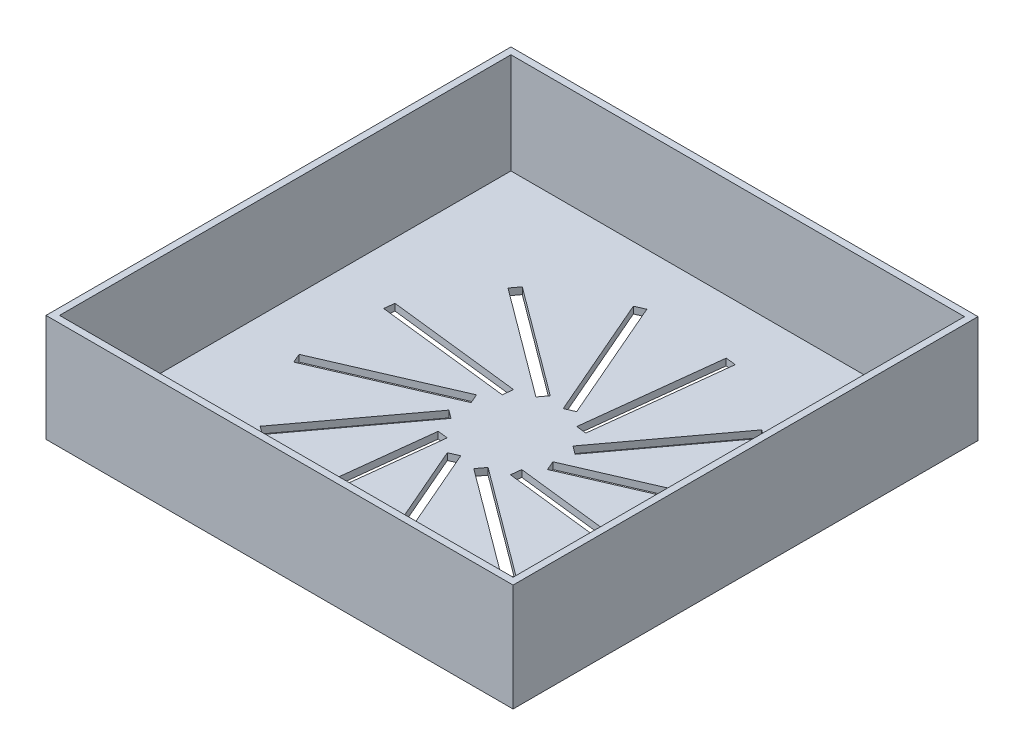
from build123d import *

# Parameters (mm, degrees)
SKETCH1_W           = 55.245
SKETCH1_H           = 54.991
BOSS_EXTRUDE1_DEPTH = 12.7
SKETCH2_W           = 53.645
SKETCH2_H           = 53.391
CUT_EXTRUDE1_DEPTH  = 11.9
CUT_EXTRUDE2_DEPTH  = 11.9


with BuildPart() as part:
    # Sketch1 → Boss-Extrude1 (new body)
    with BuildSketch(Plane(origin=(0, 0, 0), x_dir=(1, 0, 0), z_dir=(0, 1, 0))):
        with Locations((108.93085592, -3.252731307)):
            Rectangle(SKETCH1_W, SKETCH1_H)
    extrude(amount=BOSS_EXTRUDE1_DEPTH)

    # Sketch2 → Cut-Extrude1 (cut)
    with BuildSketch(Plane(origin=(0, 12.7, 0), x_dir=(1, 0, 0), z_dir=(0, 1, 0))):
        with Locations((108.93085592, -3.252731307)):
            Rectangle(SKETCH2_W, SKETCH2_H)
    extrude(amount=-CUT_EXTRUDE1_DEPTH, mode=Mode.SUBTRACT)

    # Sketch3 → Cut-Extrude2 (cut)
    with BuildSketch(Plane(origin=(0, 0.8, 0), x_dir=(1, 0, 0), z_dir=(0, 1, 0))):
        Polygon((88.811093554, 3.029967001), (104.660142286, 1.203676379), (104.521442297, 0), (88.672393566, 1.826290622), align=None)
        Polygon((94.647979747, 12.248126215), (107.460513263, 2.741987776), (106.73855736, 1.768923448), (93.926023844, 11.275061887), align=None)
        Polygon((104.311951076, 17.312843174), (110.654861369, 2.674019035), (109.543097052, 2.19229856), (103.20018676, 16.831122698), align=None)
        Polygon((115.213554228, 16.867031059), (113.387263606, 1.017982327), (112.183587227, 1.156682316), (114.009877849, 17.005731048), align=None)
        Polygon((124.431713442, 11.030144866), (114.925575003, -1.78238865), (113.952510675, -1.060432747), (123.458649114, 11.752100769), align=None)
        Polygon((129.496430401, 1.366173537), (114.857606263, -4.976736755), (114.375885787, -3.864972439), (129.014709925, 2.477937854), align=None)
        Polygon((129.050618286, -9.535429615), (113.201569555, -7.709138993), (113.340269543, -6.505462614), (129.189318275, -8.331753236), align=None)
        Polygon((123.213732093, -18.753588829), (110.401198577, -9.24745039), (111.12315448, -8.274386062), (123.935687997, -17.780524501), align=None)
        Polygon((113.549760764, -23.818305788), (107.206850472, -9.17948165), (108.318614788, -8.697761174), (114.661525081, -23.336585312), align=None)
        Polygon((102.648157613, -23.372493673), (104.474448234, -7.523444941), (105.678124613, -7.66214493), (103.851833991, -23.511193662), align=None)
        Polygon((93.429998399, -17.53560748), (102.936136838, -4.723073964), (103.909201165, -5.445029867), (94.403062726, -18.257563383), align=None)
        Polygon((88.365281439, -7.871636151), (103.004105578, -1.528725859), (103.485826053, -2.640490175), (88.847001915, -8.983400468), align=None)
    extrude(amount=-CUT_EXTRUDE2_DEPTH, mode=Mode.SUBTRACT)


solid = part.part
